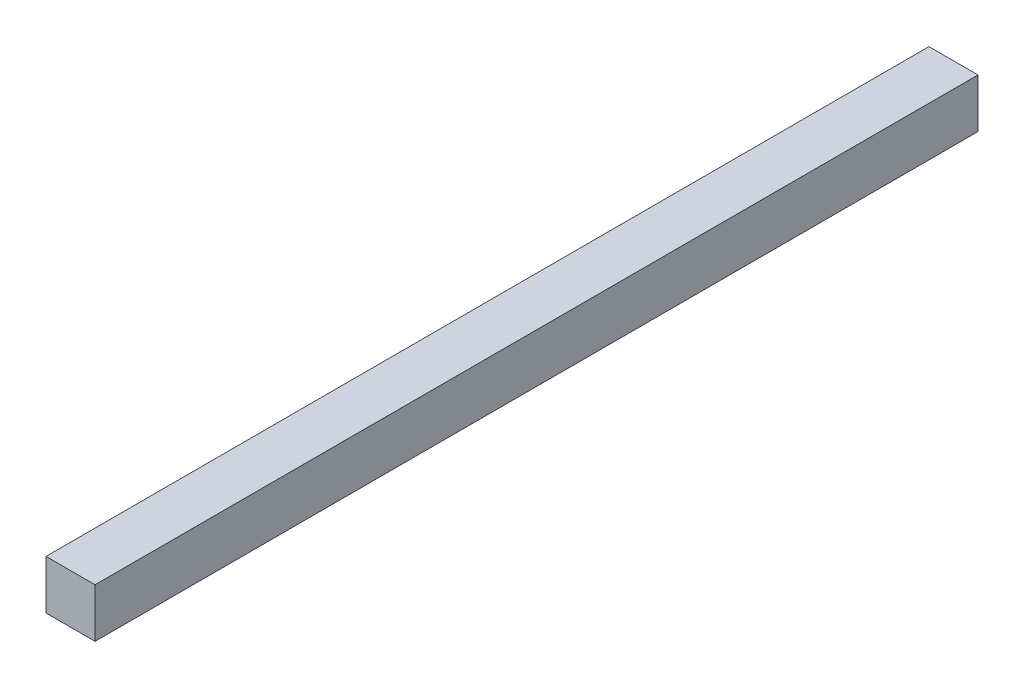
from build123d import *

# Parameters (mm, degrees)
ESQUISSE1_W        = 15
ESQUISSE1_H        = 15
BOSS_EXTRU_1_DEPTH = 270


with BuildPart() as part:
    # Esquisse1 → Boss.-Extru.1 (new body)
    with BuildSketch(Plane.XY):
        Rectangle(ESQUISSE1_W, ESQUISSE1_H)
    extrude(amount=BOSS_EXTRU_1_DEPTH)


solid = part.part
